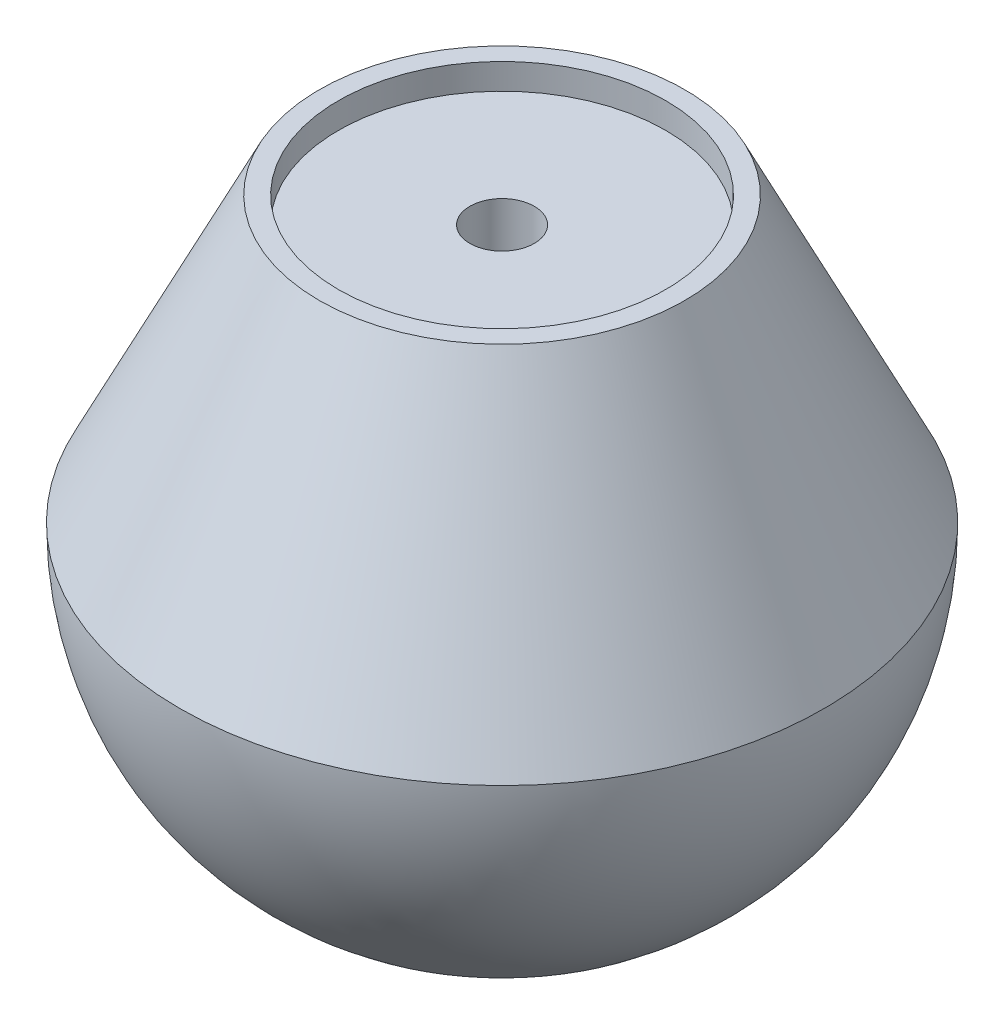
from build123d import *

# Parameters (mm, degrees)
FILLET1_R = 0.5


with BuildPart() as part:
    # Sketch1 → Revolve1 (revolve)
    with BuildSketch(Plane.XY):
        with BuildLine():
            Line((-14.176, 22), (-25, 0))
            ThreePointArc((-25, 0), (-21.46926352, -12.809009482), (-11.874342087, -22))
            Line((-11.874342087, -22), (-5, -22))
            Line((-5, -22), (-5, 0))
            Line((-5, 0), (-2.5, 0))
            Line((-2.5, 0), (-2.5, 20))
            Line((-2.5, 20), (-12.7, 20))
            Line((-12.7, 20), (-12.7, 22))
            Line((-12.7, 22), (-14.176, 22))
        make_face()
    revolve(axis=Axis((0, 0, 0), (0, -1, 0)))

    # Fillet1
    fillet1_edges = [part.edges().sort_by_distance(p)[0] for p in [
        (5, -22, 0),
        (11.874342087, -22, 0),
    ]]
    fillet(fillet1_edges, radius=FILLET1_R)


solid = part.part
